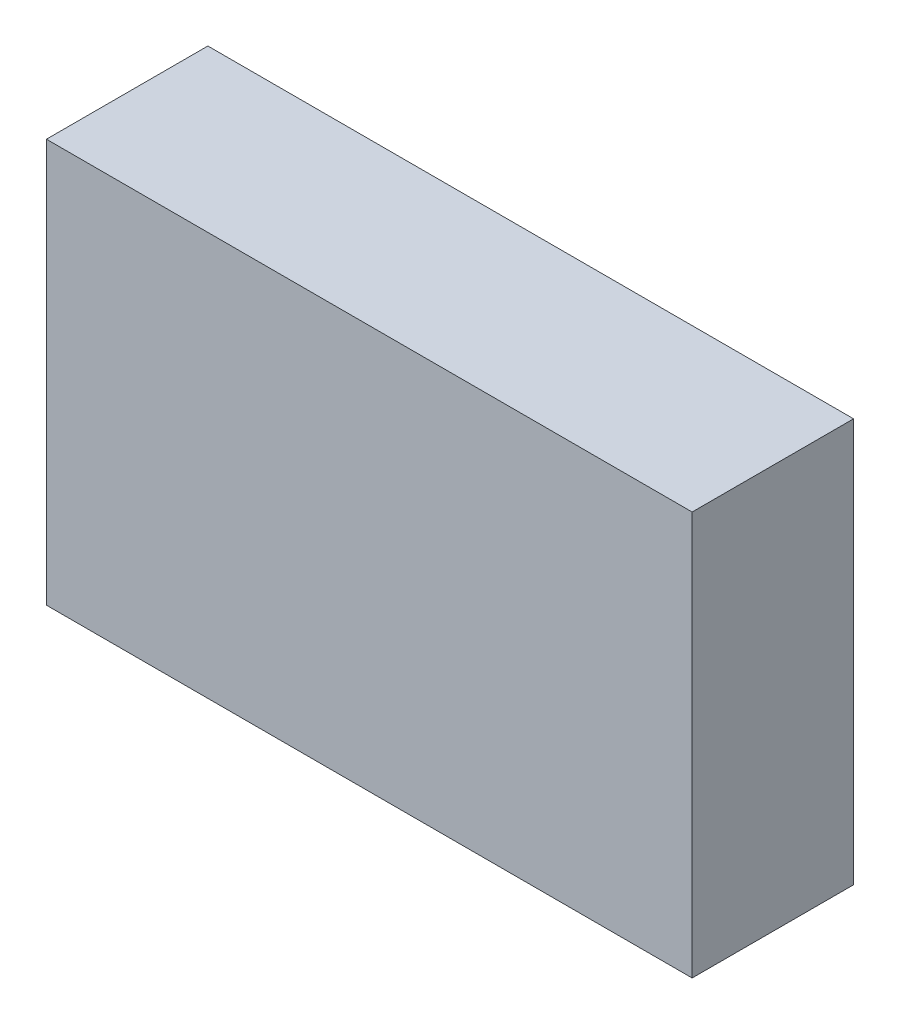
from build123d import *

# Parameters (mm, degrees)
SKETCH1_W           = 80
SKETCH1_H           = 50
BOSS_EXTRUDE1_DEPTH = 20


with BuildPart() as part:
    # Sketch1 → Boss-Extrude1 (new body)
    with BuildSketch(Plane.XY):
        with Locations((2.990654206, -4.158878505)):
            Rectangle(SKETCH1_W, SKETCH1_H)
    extrude(amount=BOSS_EXTRUDE1_DEPTH)


solid = part.part
